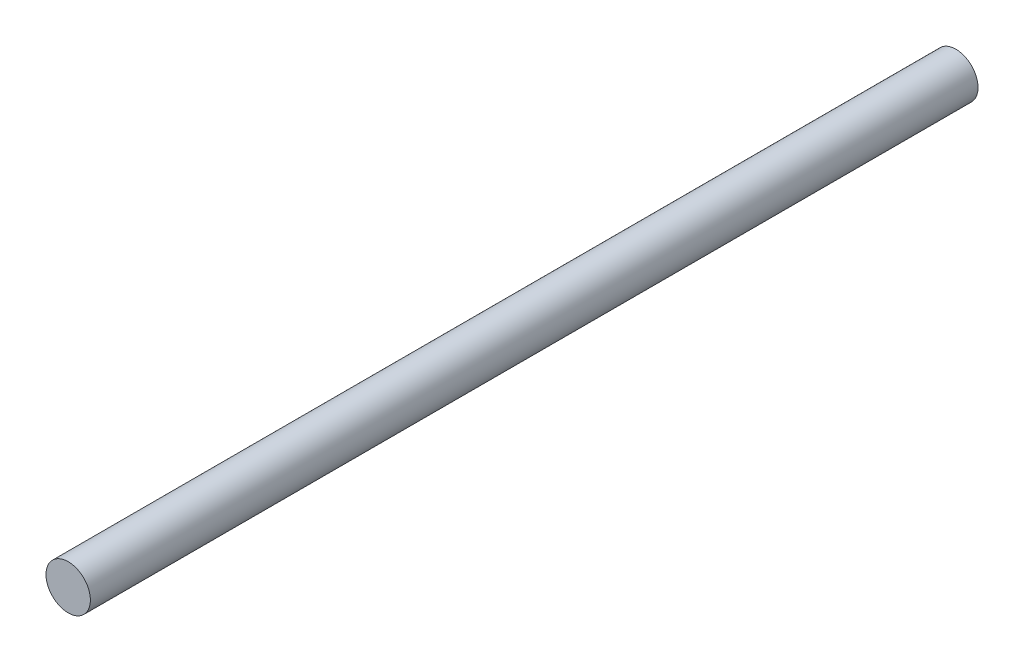
from build123d import *

# Parameters (mm, degrees)
SKETCH1_W = 1.5875
SKETCH1_H = 63.5


with BuildPart() as part:
    # Sketch1 → Revolve1 (revolve)
    with BuildSketch(Plane.XZ):
        with Locations((0.79375, 31.75)):
            Rectangle(SKETCH1_W, SKETCH1_H)
    revolve(axis=Axis((0, 0, 63.5), (0, 0, -1)))


solid = part.part
